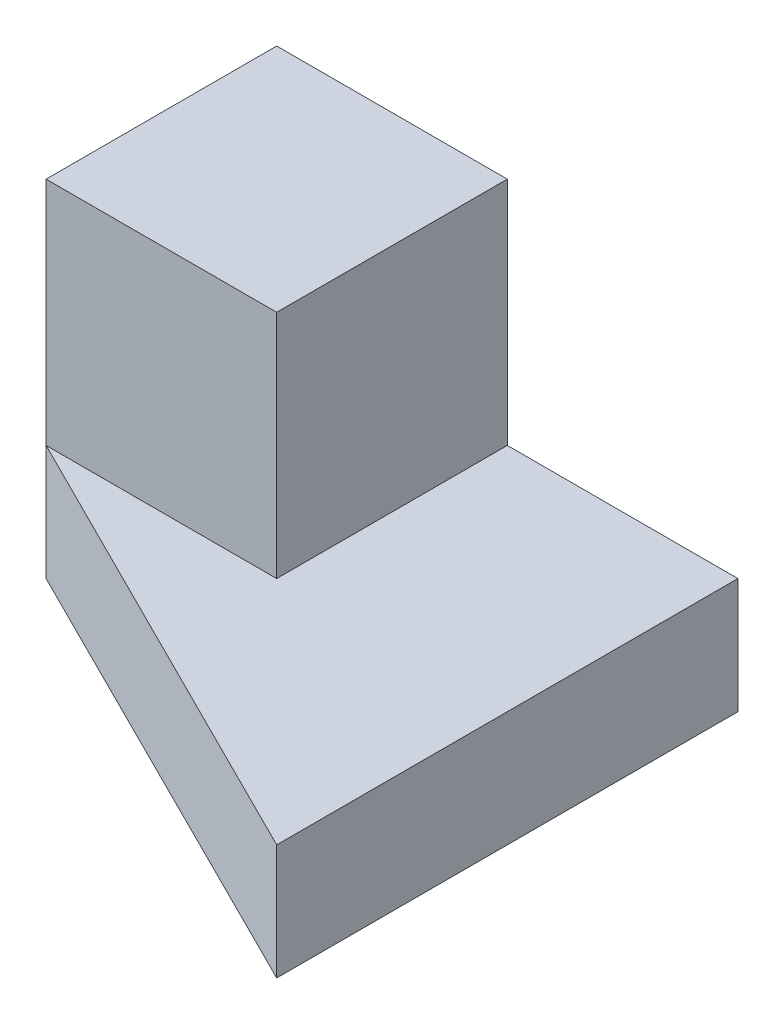
from build123d import *

# Parameters (mm, degrees)
BOSS_EXTRUDE1_DEPTH = 10
SKETCH2_W           = 20
SKETCH2_H           = 20
BOSS_EXTRUDE2_DEPTH = 20


with BuildPart() as part:
    # Sketch1 → Boss-Extrude1 (new body)
    with BuildSketch(Plane(origin=(0, 0, 0), x_dir=(1, 0, 0), z_dir=(0, 1, 0))):
        Polygon((0, 0), (0, 40), (-40, 40), (-40, 20), align=None)
    extrude(amount=BOSS_EXTRUDE1_DEPTH)

    # Sketch2 → Boss-Extrude2 (add)
    with BuildSketch(Plane(origin=(0, 10, 0), x_dir=(1, 0, 0), z_dir=(0, 1, 0))):
        with Locations((-30, 30)):
            Rectangle(SKETCH2_W, SKETCH2_H)
    extrude(amount=BOSS_EXTRUDE2_DEPTH)


solid = part.part
